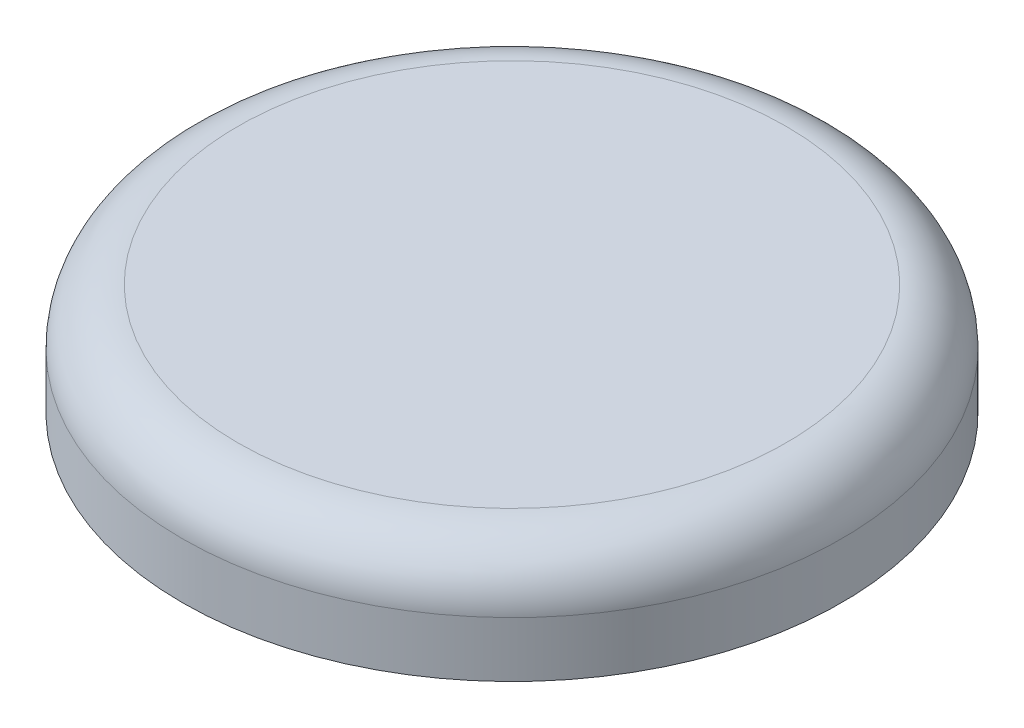
from build123d import *

# Parameters (mm, degrees)
SKETCH1_R           = 5.95
BOSS_EXTRUDE1_DEPTH = 2
FILLET1_R           = 1


with BuildPart() as part:
    # Sketch1 → Boss-Extrude1 (new body)
    with BuildSketch(Plane(origin=(0, 0, 0), x_dir=(1, 0, 0), z_dir=(0, 1, 0))):
        Circle(SKETCH1_R)
    extrude(amount=BOSS_EXTRUDE1_DEPTH)

    # Fillet1
    fillet1_edges = [part.edges().sort_by_distance(p)[0] for p in [
        (-5.95, 2, 0),
    ]]
    fillet(fillet1_edges, radius=FILLET1_R)


solid = part.part
